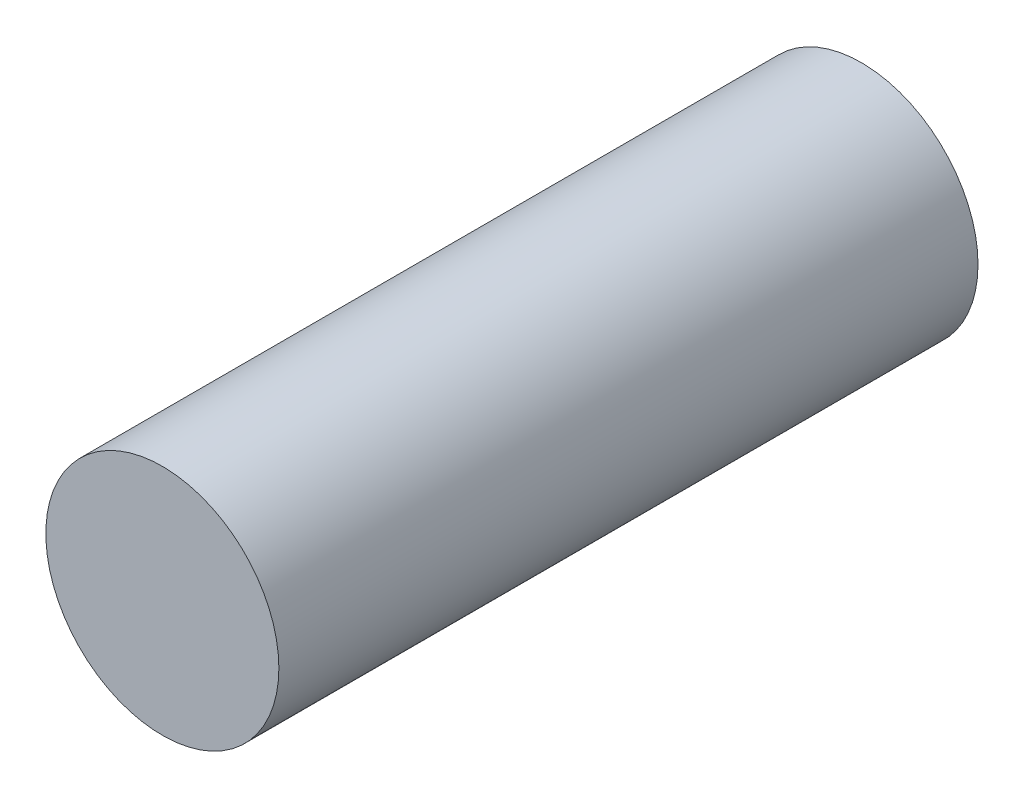
from build123d import *

# Parameters (mm, degrees)
SKETCH_1_R      = 5
EXTRUDE_1_DEPTH = 30


with BuildPart() as part:
    # 草图1 → 凸台-拉伸1 (new body)
    with BuildSketch(Plane.XY):
        Circle(SKETCH_1_R)
    extrude(amount=EXTRUDE_1_DEPTH)


solid = part.part
